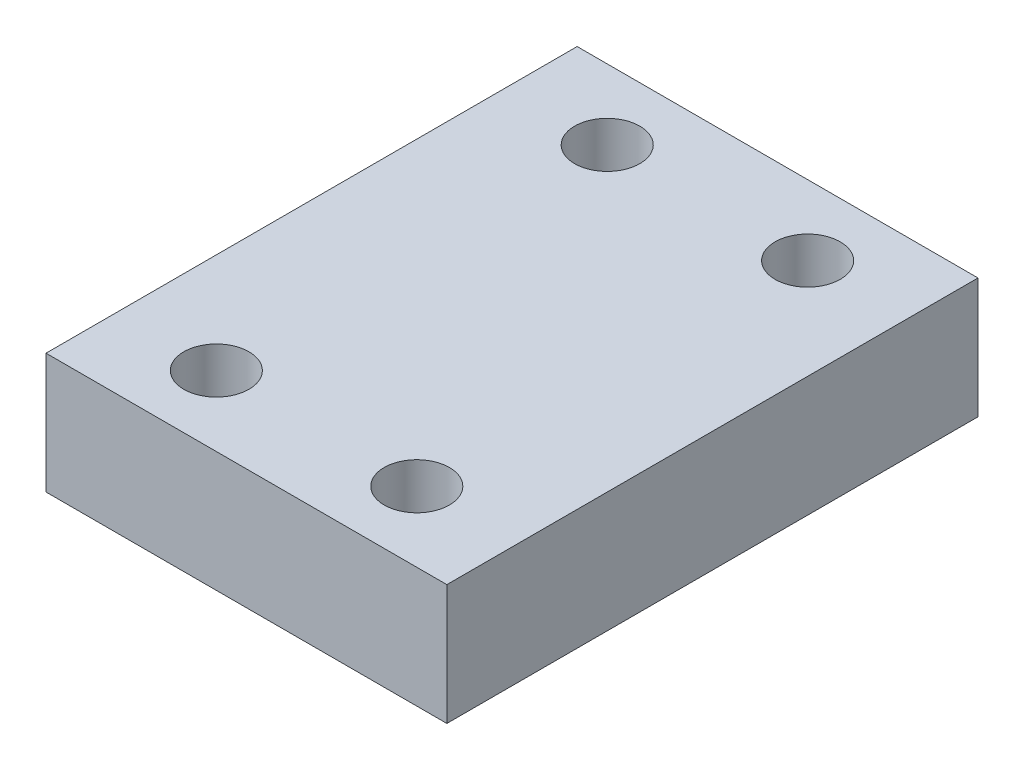
from build123d import *

# Parameters (mm, degrees)
SKETCH1_W           = 40
SKETCH1_H           = 53
BOSS_EXTRUDE1_DEPTH = 12
SKETCH2_R           = 8
CUT_EXTRUDE1_DEPTH  = 3.5
SKETCH4_R           = 4.25
CUT_EXTRUDE2_DEPTH  = 1.5
CUT_EXTRUDE3_REACH  = 14
SKETCH5_R           = 3.25


with BuildPart() as part:
    # Sketch1 → Boss-Extrude1 (new body)
    with BuildSketch(Plane(origin=(0, 0, 0), x_dir=(1, 0, 0), z_dir=(0, 1, 0))):
        with Locations((2.478549399, -6.741379093)):
            Rectangle(SKETCH1_W, SKETCH1_H)
    extrude(amount=BOSS_EXTRUDE1_DEPTH)

    # Sketch2 → Cut-Extrude1 (cut)
    with BuildSketch(Plane.XZ):
        with Locations((2.478549399, 6.741379093)):
            Circle(SKETCH2_R)
    extrude(amount=-CUT_EXTRUDE1_DEPTH, mode=Mode.SUBTRACT)

    # Sketch4 → Cut-Extrude2 (cut)
    with BuildSketch(Plane.XZ.offset(-3.5)):
        with Locations((2.478549399, 6.741379093)):
            Circle(SKETCH4_R)
    extrude(amount=-CUT_EXTRUDE2_DEPTH, mode=Mode.SUBTRACT)

    # Sketch5 → Cut-Extrude3 (cut, up to next)
    with BuildSketch(Plane(origin=(0, 12, 0), x_dir=(1, 0, 0), z_dir=(0, 1, 0)), mode=Mode.PRIVATE) as cut_extrude3_sk1:
        with Locations((-7.521450601, -26.241379093)):
            Circle(SKETCH5_R)
    cut_extrude3_tool1 = extrude(cut_extrude3_sk1.sketch, amount=-CUT_EXTRUDE3_REACH, mode=Mode.PRIVATE) & part.part
    add(cut_extrude3_tool1.solids().sort_by_distance((-7.521451, 12, 26.241379))[0], mode=Mode.SUBTRACT)
    # Sketch5 → Cut-Extrude3 (cut, up to next)
    with BuildSketch(Plane(origin=(0, 12, 0), x_dir=(1, 0, 0), z_dir=(0, 1, 0)), mode=Mode.PRIVATE) as cut_extrude3_sk2:
        with Locations((12.478549399, -26.241379093)):
            Circle(SKETCH5_R)
    cut_extrude3_tool2 = extrude(cut_extrude3_sk2.sketch, amount=-CUT_EXTRUDE3_REACH, mode=Mode.PRIVATE) & part.part
    add(cut_extrude3_tool2.solids().sort_by_distance((12.478549, 12, 26.241379))[0], mode=Mode.SUBTRACT)
    # Sketch5 → Cut-Extrude3 (cut, up to next)
    with BuildSketch(Plane(origin=(0, 12, 0), x_dir=(1, 0, 0), z_dir=(0, 1, 0)), mode=Mode.PRIVATE) as cut_extrude3_sk3:
        with Locations((-7.521450601, 12.758620907)):
            Circle(SKETCH5_R)
    cut_extrude3_tool3 = extrude(cut_extrude3_sk3.sketch, amount=-CUT_EXTRUDE3_REACH, mode=Mode.PRIVATE) & part.part
    add(cut_extrude3_tool3.solids().sort_by_distance((-7.521451, 12, -12.758621))[0], mode=Mode.SUBTRACT)
    # Sketch5 → Cut-Extrude3 (cut, up to next)
    with BuildSketch(Plane(origin=(0, 12, 0), x_dir=(1, 0, 0), z_dir=(0, 1, 0)), mode=Mode.PRIVATE) as cut_extrude3_sk4:
        with Locations((12.478549399, 12.758620907)):
            Circle(SKETCH5_R)
    cut_extrude3_tool4 = extrude(cut_extrude3_sk4.sketch, amount=-CUT_EXTRUDE3_REACH, mode=Mode.PRIVATE) & part.part
    add(cut_extrude3_tool4.solids().sort_by_distance((12.478549, 12, -12.758621))[0], mode=Mode.SUBTRACT)


solid = part.part
